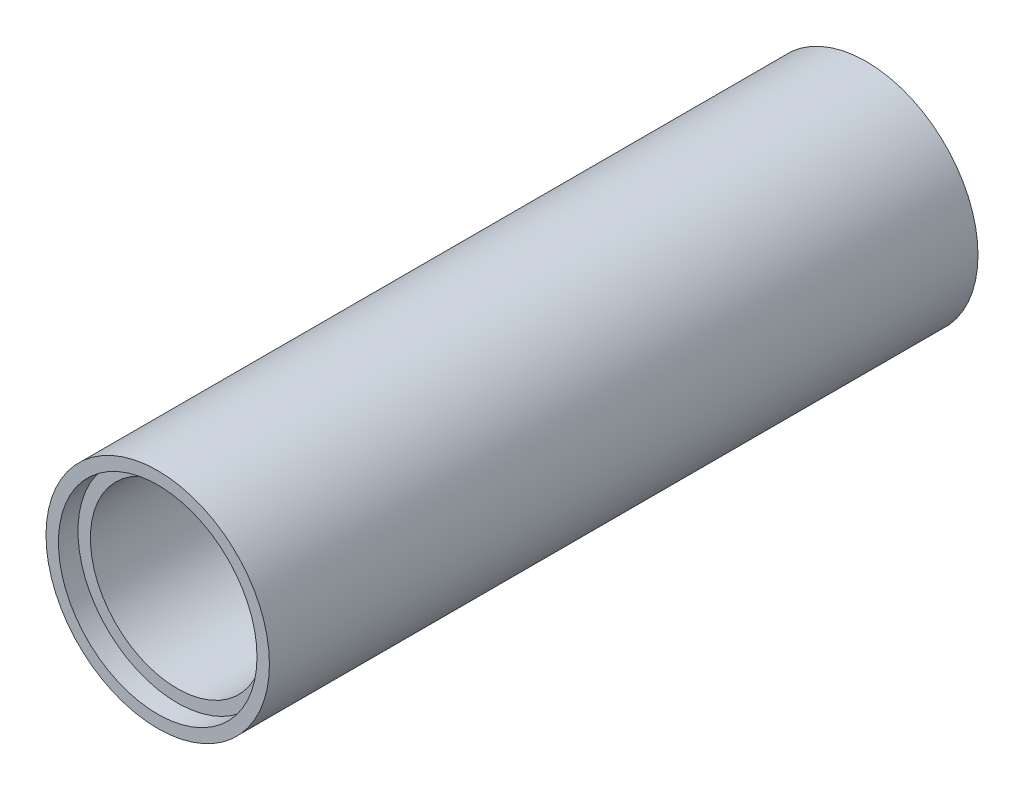
from build123d import *

# Parameters (mm, degrees)
SKETCH1_R           = 57.15
SKETCH1_R_2         = 44.45
BOSS_EXTRUDE1_DEPTH = 362.5
SKETCH2_R           = 50.8
SKETCH2_R_2         = 44.45
CUT_EXTRUDE1_DEPTH  = 10


with BuildPart() as part:
    # Sketch1 → Boss-Extrude1 (new body)
    with BuildSketch(Plane.XY):
        Circle(SKETCH1_R)
        Circle(SKETCH1_R_2, mode=Mode.SUBTRACT)
    extrude(amount=BOSS_EXTRUDE1_DEPTH)

    # Sketch2 → Cut-Extrude1 (cut)
    with BuildSketch(Plane.XY.offset(362.5)):
        Circle(SKETCH2_R)
        Circle(SKETCH2_R_2, mode=Mode.SUBTRACT)
    extrude(amount=-CUT_EXTRUDE1_DEPTH, mode=Mode.SUBTRACT)


solid = part.part
